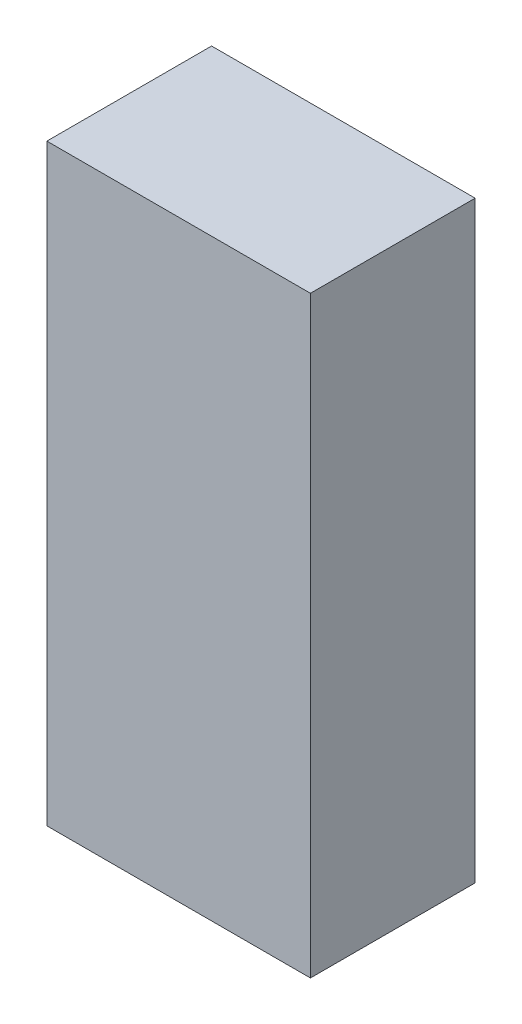
from build123d import *

# Parameters (mm, degrees)
SKETCH_1_W      = 32
SKETCH_1_H      = 72
EXTRUDE_1_DEPTH = 20


with BuildPart() as part:
    # ｽｹｯﾁ1 → ﾎﾞｽ - 押し出し1 (new body)
    with BuildSketch(Plane.XY):
        with Locations((-48.540879953, -18.459375887)):
            Rectangle(SKETCH_1_W, SKETCH_1_H)
    extrude(amount=EXTRUDE_1_DEPTH)


solid = part.part
